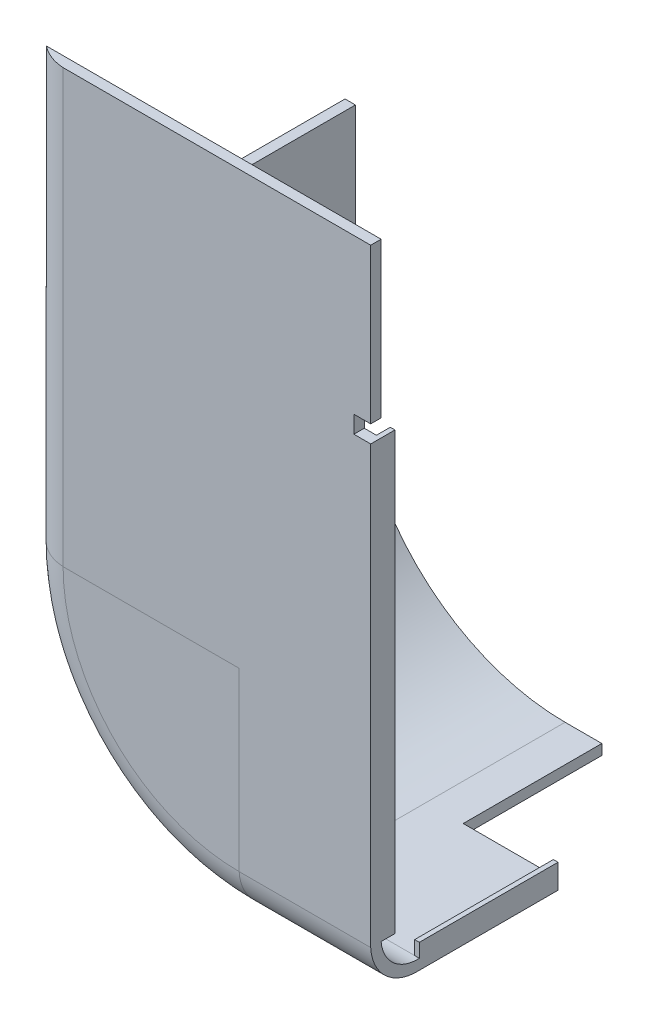
from build123d import *

# Parameters (mm, degrees)
BOSS_EXTRUDE1_DEPTH = 60
SKETCH6_W           = 76.2
SKETCH6_H           = 139.7
BOSS_EXTRUDE3_DEPTH = 3
SKETCH7_W           = 254.695348458
SKETCH7_H           = 135.329086622
CUT_EXTRUDE1_DEPTH  = 76.2
SKETCH8_W           = 10
SKETCH8_H           = 5
CUT_EXTRUDE2_DEPTH  = 172.74190537
SKETCH9_W           = 55
SKETCH9_H           = 40
CUT_EXTRUDE3_DEPTH  = 246.885251985
SKETCH10_W          = 200.764393162
SKETCH10_H          = 14.388440844
CUT_EXTRUDE4_DEPTH  = 15
BOSS_EXTRUDE4_DEPTH = 4
BOSS_EXTRUDE5_DEPTH = 4
SKETCH13_W          = 181.59007752
SKETCH13_H          = 354.992238287
CUT_EXTRUDE5_DEPTH  = 101.75


with BuildPart() as part:
    # Sketch1 → Boss-Extrude1 (new body)
    with BuildSketch(Plane.XY):
        with BuildLine():
            Line((-101.6, 101.6), (-101.6, -38.1))
            ThreePointArc((-101.6, -38.1), (-83.001280605, -83.001280605), (-38.1, -101.6))
            Line((-38.1, -101.6), (38.1, -101.6))
            ThreePointArc((38.1, -101.6), (83.001280605, -83.001280605), (101.6, -38.1))
            Line((101.6, -38.1), (101.6, 101.6))
            Line((101.6, 101.6), (-101.6, 101.6))
        make_face()
        with BuildLine():
            Line((-98.6, 98.6), (-98.6, -38.1))
            ThreePointArc((-98.6, -38.1), (-80.879960262, -80.879960262), (-38.1, -98.6))
            Line((-38.1, -98.6), (38.1, -98.6))
            ThreePointArc((38.1, -98.6), (80.879960262, -80.879960262), (98.6, -38.1))
            Line((98.6, -38.1), (98.6, 98.6))
            Line((98.6, 98.6), (-98.6, 98.6))
        make_face(mode=Mode.SUBTRACT)
    extrude(amount=BOSS_EXTRUDE1_DEPTH)

    # Sweep2: sweep along a path in Sketch5
    with BuildLine(Plane.XY.offset(60)) as sweep2_path:
        Line((-100.1, 101.6), (-100.1, -38.1))
        ThreePointArc((-100.1, -38.1), (-81.940620434, -81.940620434), (-38.1, -100.1))
        Line((-38.1, -100.1), (38.1, -100.1))
        ThreePointArc((38.1, -100.1), (81.940620434, -81.940620434), (100.1, -38.1))
        Line((100.1, -38.1), (100.1, 101.6))
    # Sketch3 → Sweep2 (sweep)
    with BuildSketch(Plane(origin=(0, 101.6, 0), x_dir=(1, 0, 0), z_dir=(0, 1, 0))):
        with BuildLine():
            Line((-38.1, -91.039099262), (-88.9, -91.039099262))
            ThreePointArc((-88.9, -91.039099262), (-95.981959893, -87.480761361), (-98.6, -80))
            Line((-98.6, -80), (-98.6, -60))
            Line((-98.6, -60), (-101.6, -60))
            Line((-101.6, -60), (-101.6, -80))
            ThreePointArc((-101.6, -80), (-98.157592659, -89.649805752), (-88.9, -94.039099262))
            Line((-88.9, -94.039099262), (-38.1, -94.039099262))
            Line((-38.1, -94.039099262), (-38.1, -91.039099262))
        make_face()
    sweep(path=sweep2_path.line)

    # Sketch6 → Boss-Extrude3 (add)
    with BuildSketch(Plane.XY.offset(94.039099262)):
        with Locations((0, 31.75)):
            Rectangle(SKETCH6_W, SKETCH6_H)
    extrude(amount=-BOSS_EXTRUDE3_DEPTH)

    # Sketch7 → Cut-Extrude1 (cut)
    with BuildSketch(Plane(origin=(0, 101.6, 0), x_dir=(1, 0, 0), z_dir=(0, 1, 0))):
        with Locations((-4.889183354, -23.374555951)):
            Rectangle(SKETCH7_W, SKETCH7_H)
    extrude(amount=-CUT_EXTRUDE1_DEPTH, mode=Mode.SUBTRACT)

    # Sketch8 → Cut-Extrude2 (cut, through all)
    with BuildSketch(Plane.XY.offset(94.039099262)):
        with Locations((0, 39.440517612)):
            Rectangle(SKETCH8_W, SKETCH8_H)
    extrude(amount=-CUT_EXTRUDE2_DEPTH, mode=Mode.SUBTRACT)

    # Sketch9 → Cut-Extrude3 (cut, through all)
    with BuildSketch(Plane(origin=(0, -101.6, 0), x_dir=(-1, 0, 0), z_dir=(0, -1, 0))):
        with Locations((0, -20)):
            Rectangle(SKETCH9_W, SKETCH9_H)
    extrude(amount=-CUT_EXTRUDE3_DEPTH, mode=Mode.SUBTRACT)

    # Sketch10 → Cut-Extrude4 (cut)
    with BuildSketch(Plane(origin=(0, 101.6, 0), x_dir=(1, 0, 0), z_dir=(0, 1, 0))):
        with Locations((0, -94.039099262)):
            Rectangle(SKETCH10_W, SKETCH10_H)
    extrude(amount=-CUT_EXTRUDE4_DEPTH, mode=Mode.SUBTRACT)

    # Sketch11 → Boss-Extrude4 (add)
    with BuildSketch(Plane(origin=(0, -98.6, 0), x_dir=(1, 0, 0), z_dir=(0, 1, 0))):
        Polygon((0, -80), (1.5, -80), (1.5, -40), (0, -40), (-1.5, -40), (-1.5, -80), align=None)
    extrude(amount=BOSS_EXTRUDE4_DEPTH)

    # Sketch12 → Boss-Extrude5 (add)
    with BuildSketch(Plane(origin=(0, 0, 91.039099262), x_dir=(-1, 0, 0), z_dir=(0, 0, -1))):
        Polygon((-1.5, -88.9), (0, -88.9), (1.5, -88.9), (1.5, 36.940517612), (-1.5, 36.940517612), align=None)
    extrude(amount=BOSS_EXTRUDE5_DEPTH)

    # Sketch13 → Cut-Extrude5 (cut)
    with BuildSketch(Plane(origin=(101.6, 0, 0), x_dir=(0, 0, -1), z_dir=(1, 0, 0))):
        with Locations((-39.565471337, -8.440264941)):
            Rectangle(SKETCH13_W, SKETCH13_H)
    extrude(amount=-CUT_EXTRUDE5_DEPTH, mode=Mode.SUBTRACT)


with BuildPart() as cut_extrude5_kept_piece:
    # of the separate pieces the step leaves, the one the design keeps (cut_extrude5_pieces_kept)
    add(part.part.solids().sort_by_distance((-101.6, 25.4, 0))[0])


solid = cut_extrude5_kept_piece.part
